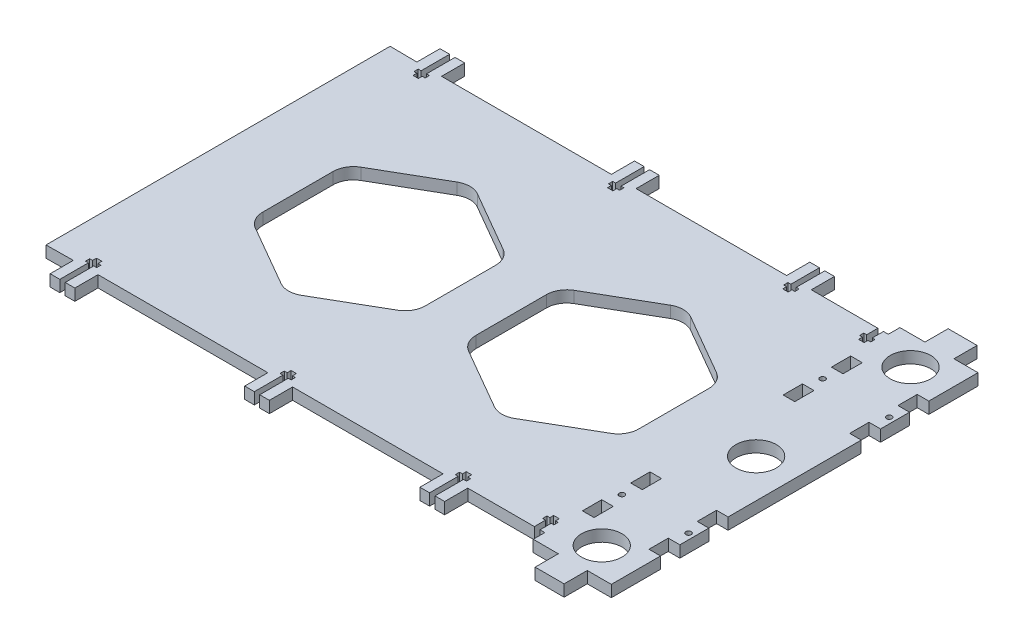
from build123d import *

# Parameters (mm, degrees)
SKETCH_1_R      = 10.5
SKETCH_1_R_2    = 1.4
SKETCH_1_W      = 6
SKETCH_1_H      = 10
EXTRUDE_1_DEPTH = 6


with BuildPart() as part:
    # Эскиз1 → Бобышка-Вытянуть1 (new body)
    with BuildSketch(Plane(origin=(0, 0, 0), x_dir=(1, 0, 0), z_dir=(0, 1, 0))):
        Polygon((-117.473635401, -101.4099491), (-117.473635401, -89.4099491), (-29.473635401, -89.409373018), (-29.473635401, -101.409373018), (-24.473635401, -101.409373018), (-24.473635401, -86.609373018), (-25.973635401, -86.609373018), (-25.973635401, -84.409373018), (-24.473635401, -84.409373018), (-24.473635401, -82.409373018), (-21.673635401, -82.409373018), (-21.673635401, -84.409373018), (-20.173635401, -84.409373018), (-20.173635401, -86.609373018), (-21.673635401, -86.609373018), (-21.673635401, -101.409373018), (-16.673635401, -101.409373018), (-16.673635401, -89.4099491), (61.326364599, -89.4099491), (61.326364599, -101.4099491), (66.326364599, -101.4099491), (66.326364599, -86.6099491), (64.826364599, -86.6099491), (64.826364599, -84.4099491), (66.326364599, -84.4099491), (66.326364599, -82.4099491), (69.126364599, -82.4099491), (69.126364599, -84.4099491), (70.626364599, -84.4099491), (70.626364599, -86.6099491), (69.126364599, -86.6099491), (69.126364599, -101.4099491), (74.126364599, -101.4099491), (74.126364599, -89.4099491), (108.626364599, -89.4099491), (108.626364599, -83.6099491), (107.126364599, -83.6099491), (107.126364599, -81.4099491), (108.626364599, -81.4099491), (108.626364599, -79.4099491), (111.535743516, -79.4099491), (111.535743516, -81.4099491), (112.926364599, -81.4099491), (112.926364599, -83.6099491), (111.535743516, -83.6099491), (111.535743516, -89.4099491), (114.035743516, -89.4099491), (114.035743516, -95.4099491), (120.035743516, -95.4099491), (127.035743516, -95.4099491), (127.035743516, -107.4099491), (142.035743516, -107.4099491), (142.035743516, -95.4099491), (154.504146002, -95.4099491), (154.504146002, -69.9099491), (148.504146002, -69.9099491), (148.504146002, -59.9099491), (154.504146002, -59.9099491), (154.504146002, -44.9099491), (148.504146002, -44.9099491), (148.504146002, -34.9099491), (154.504146002, -34.9099491), (154.504146002, 34.0900509), (148.504146002, 34.0900509), (148.504146002, 44.0900509), (154.504146002, 44.0900509), (154.504146002, 59.0900509), (148.504146002, 59.0900509), (148.504146002, 69.0900509), (154.504146002, 69.0900509), (154.504146002, 94.5900509), (142.035743516, 94.5900509), (142.035743516, 106.5900509), (127.035743516, 106.5900509), (127.035743516, 94.5900509), (120.035743516, 94.5900509), (114.035743516, 94.5900509), (114.035743516, 88.5900509), (111.535743516, 88.5900509), (111.535743516, 82.7900509), (112.926364599, 82.7900509), (112.926364599, 80.5900509), (111.535743516, 80.5900509), (111.535743516, 78.5900509), (108.626364599, 78.5900509), (108.626364599, 80.5900509), (107.126364599, 80.5900509), (107.126364599, 82.7900509), (108.626364599, 82.7900509), (108.626364599, 88.5900509), (74.126364599, 88.5900509), (74.126364599, 100.5900509), (69.126364599, 100.5900509), (69.126364599, 85.7900509), (70.626364599, 85.7900509), (70.626364599, 83.5900509), (69.126364599, 83.5900509), (69.126364599, 81.5900509), (66.326364599, 81.5900509), (66.326364599, 83.5900509), (64.826364599, 83.5900509), (64.826364599, 85.7900509), (66.326364599, 85.7900509), (66.326364599, 100.5900509), (61.326364599, 100.5900509), (61.326364599, 88.5900509), (-16.673635401, 88.5900509), (-16.673635401, 100.589474817), (-21.673635401, 100.589474817), (-21.673635401, 85.789474817), (-20.173635401, 85.789474817), (-20.173635401, 83.589474817), (-21.673635401, 83.589474817), (-21.673635401, 81.589474817), (-24.473635401, 81.589474817), (-24.473635401, 83.589474817), (-25.973635401, 83.589474817), (-25.973635401, 85.789474817), (-24.473635401, 85.789474817), (-24.473635401, 100.589474817), (-29.473635401, 100.589474817), (-29.473635401, 88.589474817), (-117.473635401, 88.5900509), (-117.473635401, 100.5900509), (-122.473635401, 100.5900509), (-122.473635401, 85.7900509), (-120.973635401, 85.7900509), (-120.973635401, 83.5900509), (-122.473635401, 83.5900509), (-122.473635401, 81.5900509), (-125.273635401, 81.5900509), (-125.273635401, 83.5900509), (-126.773635401, 83.5900509), (-126.773635401, 85.7900509), (-125.273635401, 85.7900509), (-125.273635401, 100.5900509), (-130.273635401, 100.5900509), (-130.273635401, 88.5900509), (-144.273635401, 88.746984561), (-144.273635401, -89.566882761), (-130.273635401, -89.4099491), (-130.273635401, -101.4099491), (-125.273635401, -101.4099491), (-125.273635401, -86.6099491), (-126.773635401, -86.6099491), (-126.773635401, -84.4099491), (-125.273635401, -84.4099491), (-125.273635401, -82.4099491), (-122.473635401, -82.4099491), (-122.473635401, -84.4099491), (-120.973635401, -84.4099491), (-120.973635401, -86.6099491), (-122.473635401, -86.6099491), (-122.473635401, -101.4099491), align=None)
        with Locations((134.535743516, 79.5900509)):
            Circle(SKETCH_1_R, mode=Mode.SUBTRACT)
        with Locations((134.535743516, -0.4099491)):
            Circle(SKETCH_1_R, mode=Mode.SUBTRACT)
        with Locations((151.504146002, 51.5900509)):
            Circle(SKETCH_1_R_2, mode=Mode.SUBTRACT)
        with Locations((116.978141574, 51.5900509)):
            Circle(SKETCH_1_R_2, mode=Mode.SUBTRACT)
        with Locations((116.978141574, -52.4099491)):
            Circle(SKETCH_1_R_2, mode=Mode.SUBTRACT)
        with Locations((151.504146002, -52.4099491)):
            Circle(SKETCH_1_R_2, mode=Mode.SUBTRACT)
        with Locations((134.535743516, -80.4099491)):
            Circle(SKETCH_1_R, mode=Mode.SUBTRACT)
        with BuildLine():
            Line((-23.916948741, 26.938229251), (-55.495903408, 45.170347229))
            ThreePointArc((-55.495903408, 45.170347229), (-60.759062907, 46.580606949), (-66.022222533, 45.170347705))
            Line((-66.022222533, 45.170347705), (-97.601176456, 26.938228368))
            ThreePointArc((-97.601176456, 26.938228368), (-101.454076716, 23.085328612), (-102.864336112, 17.822169354))
            Line((-102.864336112, 17.822169354), (-102.864336739, -0.4099491))
            Line((-102.864336739, -0.4099491), (-102.864336112, -18.642067554))
            ThreePointArc((-102.864336112, -18.642067554), (-101.454076716, -23.905226813), (-97.601176456, -27.758126569))
            Line((-97.601176456, -27.758126569), (-66.022222533, -45.990245906))
            ThreePointArc((-66.022222533, -45.990245906), (-60.759062907, -47.40050515), (-55.495903408, -45.99024543))
            Line((-55.495903408, -45.99024543), (-23.916948741, -27.758127452))
            ThreePointArc((-23.916948741, -27.758127452), (-20.064048696, -23.905227053), (-18.653789757, -18.642067359))
            Line((-18.653789757, -18.642067359), (-18.653789757, 17.822169158))
            ThreePointArc((-18.653789757, 17.822169158), (-20.064048696, 23.085328852), (-23.916948741, 26.938229251))
        make_face(mode=Mode.SUBTRACT)
        with BuildLine():
            Line((91.872555356, -0.4099491), (91.872555984, 17.822170089))
            ThreePointArc((91.872555984, 17.822170089), (90.462296282, 23.08532917), (86.609396157, 26.938228929))
            Line((86.609396157, 26.938228929), (55.030441843, 45.170346703))
            ThreePointArc((55.030441843, 45.170346703), (49.767282136, 46.580606642), (44.504122247, 45.170347383))
            Line((44.504122247, 45.170347383), (12.925166834, 26.938228046))
            ThreePointArc((12.925166834, 26.938228046), (9.072267233, 23.08532824), (7.66200811, 17.822169354))
            Line((7.66200811, 17.822169354), (7.66200811, -18.642067554))
            ThreePointArc((7.66200811, -18.642067554), (9.072267233, -23.90522644), (12.925166834, -27.758126246))
            Line((12.925166834, -27.758126246), (44.504122247, -45.990245583))
            ThreePointArc((44.504122247, -45.990245583), (49.767282136, -47.400504843), (55.030441843, -45.990244903))
            Line((55.030441843, -45.990244903), (86.609396157, -27.758127129))
            ThreePointArc((86.609396157, -27.758127129), (90.462296282, -23.90522737), (91.872555984, -18.64206829))
            Line((91.872555984, -18.64206829), (91.872555356, -0.4099491))
        make_face(mode=Mode.SUBTRACT)
        with Locations((117.035743516, 64.0900509)):
            Rectangle(SKETCH_1_W, SKETCH_1_H, mode=Mode.SUBTRACT)
        with Locations((117.035743516, 39.0900509)):
            Rectangle(SKETCH_1_W, SKETCH_1_H, mode=Mode.SUBTRACT)
        with Locations((117.035743516, -39.9099491)):
            Rectangle(SKETCH_1_W, SKETCH_1_H, mode=Mode.SUBTRACT)
        with Locations((117.035743516, -64.9099491)):
            Rectangle(SKETCH_1_W, SKETCH_1_H, mode=Mode.SUBTRACT)
    extrude(amount=EXTRUDE_1_DEPTH)


solid = part.part
